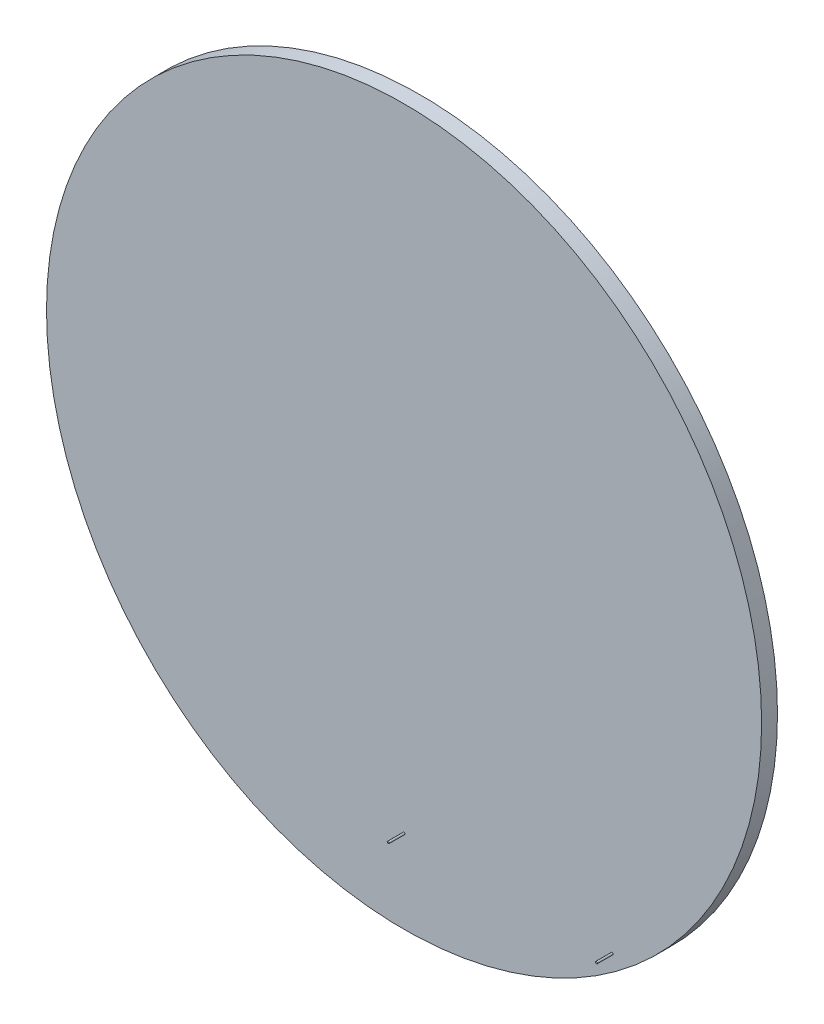
from build123d import *

# Parameters (mm, degrees)
SKETCH1_R           = 572.6684
BOSS_EXTRUDE1_DEPTH = 25.4
SKETCH2_R           = 1.5875
BOSS_EXTRUDE2_DEPTH = 25.4


with BuildPart() as part:
    # Sketch1 → Boss-Extrude1 (new body)
    with BuildSketch(Plane.XY):
        Circle(SKETCH1_R)
    extrude(amount=BOSS_EXTRUDE1_DEPTH)

    # Sketch2 → Boss-Extrude2 (add)
    with BuildSketch(Plane.XY.offset(25.4)):
        with Locations((0, -439.3184)):
            Circle(SKETCH2_R)
        with Locations((333.375, -439.3184)):
            Circle(SKETCH2_R)
    extrude(amount=BOSS_EXTRUDE2_DEPTH)


solid = part.part
